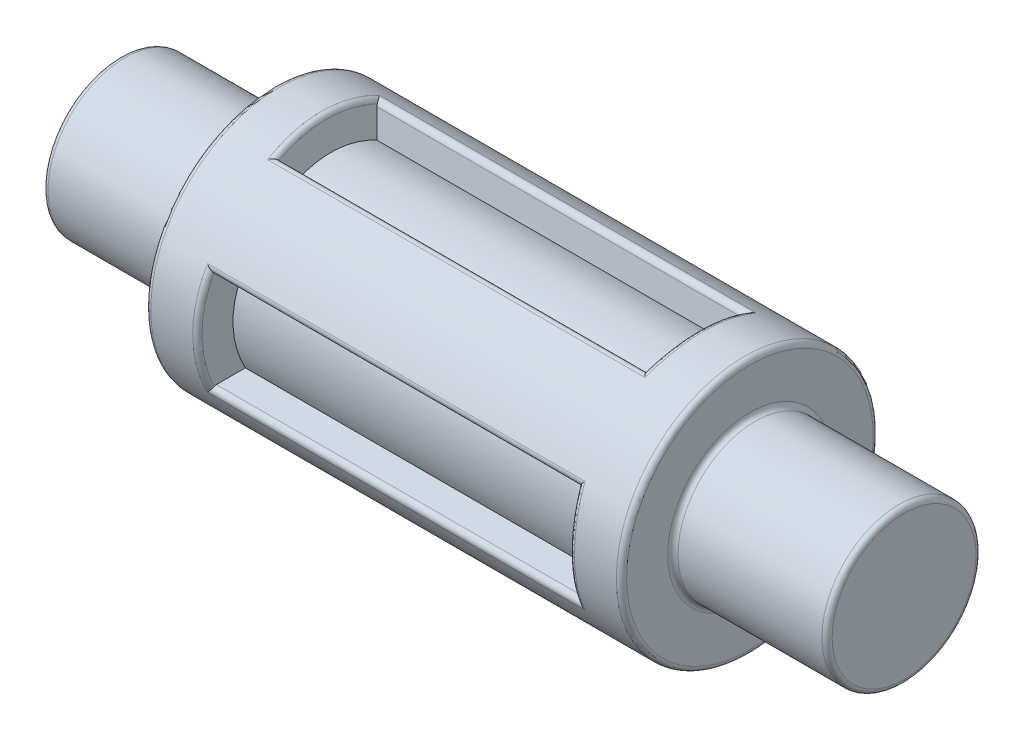
from build123d import *

# Parameters (mm, degrees)
FILLET1_R                   = 0.1
SKETCH2_W                   = 7.26
SKETCH2_H                   = 2
CUT_EXTRUDE1_DEPTH          = 0.8
CUT_EXTRUDE1_DRAFT          = -10
FILLET2_R                   = 0.1
CIRPATTERN1_COPY_1_SKETCH_W = 7.26
CIRPATTERN1_COPY_1_SKETCH_H = 2
CIRPATTERN1_COPY_1_DEPTH    = 0.8
CIRPATTERN1_COPY_1_DRAFT    = -10
CIRPATTERN1_COPY_2_SKETCH_W = 7.26
CIRPATTERN1_COPY_2_SKETCH_H = 2
CIRPATTERN1_COPY_2_DEPTH    = 0.8
CIRPATTERN1_COPY_2_DRAFT    = -10
CIRPATTERN1_COPY_3_SKETCH_W = 7.26
CIRPATTERN1_COPY_3_SKETCH_H = 2
CIRPATTERN1_COPY_3_DEPTH    = 0.8
CIRPATTERN1_COPY_3_DRAFT    = -10
FILLET2_OF_CIRPATTERN1_R    = 0.1
BOSS_EXTRUDE1_REACH         = 14.76
SKETCH3_R                   = 1.904671941


with BuildPart() as part:
    # Sketch1 → Revolve1 (revolve)
    with BuildSketch(Plane(origin=(0, 0, 0), x_dir=(1, 0, 0), z_dir=(0, 1, 0)), mode=Mode.PRIVATE) as revolve1_sk:
        Polygon((0, 0), (0, 1.5), (3, 1.5), (3, 2.5), (12.26, 2.5), (12.26, 1.5), (15.26, 1.5), (15.26, 0), align=None)
    revolve(revolve1_sk.sketch.rotate(Axis((0, 0, 0), (1, 0, 0)), 180), axis=Axis((0, 0, 0), (1, 0, 0)))

    # Fillet1
    fillet1_edges = [part.edges().sort_by_distance(p)[0] for p in [
        (15.26, 0, -1.5),
        (12.26, 0, -1.5),
        (12.26, 0, -2.5),
        (3, 0, -2.5),
        (3, 0, -1.5),
        (0, 0, -1.5),
    ]]
    fillet(fillet1_edges, radius=FILLET1_R)


with BuildPart() as cut_extrude1_tool:
    # Sketch2 → Cut-Extrude1 (with draft: the straight prism first)
    with BuildSketch(Plane(origin=(0, 2.5, 0), x_dir=(-1, 0, 0), z_dir=(0, 1, 0))):
        with Locations((-7.63, 0)):
            Rectangle(SKETCH2_W, SKETCH2_H)
    extrude(amount=-CUT_EXTRUDE1_DEPTH)
    # Cut-Extrude1: the draft: its side faces are tilted about the plane it starts from
    cut_extrude1_sides = [cut_extrude1_tool.faces().sort_by_distance(p)[0] for p in [
        (7.63, 2.1, -1),
        (4, 2.1, 0),
        (7.63, 2.1, 1),
        (11.26, 2.1, 0),
    ]]
    draft(cut_extrude1_sides, Plane(origin=(0, 2.5, 0), x_dir=(-1, 0, 0), z_dir=(0, 1, 0)), CUT_EXTRUDE1_DRAFT)


with BuildPart() as part_1:
    add(part.part)

    # Cut-Extrude1: cut by cut_extrude1_tool
    add(cut_extrude1_tool.part, mode=Mode.SUBTRACT)

    # Fillet2
    fillet2_edges = [part_1.edges().sort_by_distance(p)[0] for p in [
        (11.251349876, 2.45094271, 0.492828398),
        (4.008650124, 2.45094271, 0.492828398),
        (7.63, 2.305920994, 0.965778635),
        (7.63, 2.305920994, -0.965778635),
    ]]
    fillet(fillet2_edges, radius=FILLET2_R)


with BuildPart() as cirpattern1_copy_1_tool:
    # CirPattern1 copy 1 sketch → CirPattern1 copy 1 (with draft: the straight prism first)
    with BuildSketch(Plane(origin=(0, 0, 2.5), x_dir=(-1, 0, 0), z_dir=(0, 0, 1))):
        with Locations((-7.63, 0)):
            Rectangle(CIRPATTERN1_COPY_1_SKETCH_W, CIRPATTERN1_COPY_1_SKETCH_H)
    extrude(amount=-CIRPATTERN1_COPY_1_DEPTH)
    # CirPattern1 copy 1: the draft: its side faces are tilted about the plane it starts from
    cirpattern1_copy_1_sides = [cirpattern1_copy_1_tool.faces().sort_by_distance(p)[0] for p in [
        (7.63, 1, 2.1),
        (4, 0, 2.1),
        (7.63, -1, 2.1),
        (11.26, 0, 2.1),
    ]]
    draft(cirpattern1_copy_1_sides, Plane(origin=(0, 0, 2.5), x_dir=(-1, 0, 0), z_dir=(0, 0, 1)), CIRPATTERN1_COPY_1_DRAFT)


with BuildPart() as part_2:
    add(part_1.part)

    # CirPattern1 copy 1: cut by cirpattern1_copy_1_tool
    add(cirpattern1_copy_1_tool.part, mode=Mode.SUBTRACT)


with BuildPart() as cirpattern1_copy_2_tool:
    # CirPattern1 copy 2 sketch → CirPattern1 copy 2 (with draft: the straight prism first)
    with BuildSketch(Plane(origin=(0, -2.5, 0), x_dir=(-1, 0, 0), z_dir=(0, -1, 0))):
        with Locations((-7.63, 0)):
            Rectangle(CIRPATTERN1_COPY_2_SKETCH_W, CIRPATTERN1_COPY_2_SKETCH_H)
    extrude(amount=-CIRPATTERN1_COPY_2_DEPTH)
    # CirPattern1 copy 2: the draft: its side faces are tilted about the plane it starts from
    cirpattern1_copy_2_sides = [cirpattern1_copy_2_tool.faces().sort_by_distance(p)[0] for p in [
        (7.63, -2.1, 1),
        (4, -2.1, 0),
        (7.63, -2.1, -1),
        (11.26, -2.1, 0),
    ]]
    draft(cirpattern1_copy_2_sides, Plane(origin=(0, -2.5, 0), x_dir=(-1, 0, 0), z_dir=(0, -1, 0)), CIRPATTERN1_COPY_2_DRAFT)


with BuildPart() as part_3:
    add(part_2.part)

    # CirPattern1 copy 2: cut by cirpattern1_copy_2_tool
    add(cirpattern1_copy_2_tool.part, mode=Mode.SUBTRACT)


with BuildPart() as cirpattern1_copy_3_tool:
    # CirPattern1 copy 3 sketch → CirPattern1 copy 3 (with draft: the straight prism first)
    with BuildSketch(Plane(origin=(0, 0, -2.5), x_dir=(-1, 0, 0), z_dir=(0, 0, -1))):
        with Locations((-7.63, 0)):
            Rectangle(CIRPATTERN1_COPY_3_SKETCH_W, CIRPATTERN1_COPY_3_SKETCH_H)
    extrude(amount=-CIRPATTERN1_COPY_3_DEPTH)
    # CirPattern1 copy 3: the draft: its side faces are tilted about the plane it starts from
    cirpattern1_copy_3_sides = [cirpattern1_copy_3_tool.faces().sort_by_distance(p)[0] for p in [
        (7.63, -1, -2.1),
        (4, 0, -2.1),
        (7.63, 1, -2.1),
        (11.26, 0, -2.1),
    ]]
    draft(cirpattern1_copy_3_sides, Plane(origin=(0, 0, -2.5), x_dir=(-1, 0, 0), z_dir=(0, 0, -1)), CIRPATTERN1_COPY_3_DRAFT)


with BuildPart() as part_4:
    add(part_3.part)

    # CirPattern1 copy 3: cut by cirpattern1_copy_3_tool
    add(cirpattern1_copy_3_tool.part, mode=Mode.SUBTRACT)

    # Fillet2 of CirPattern1
    fillet2_of_cirpattern1_edges = [part_4.edges().sort_by_distance(p)[0] for p in [
        (11.251349876, -0.492828398, 2.45094271),
        (4.008650124, -0.492828398, 2.45094271),
        (7.63, -0.965778635, 2.305920994),
        (7.63, 0.965778635, 2.305920994),
        (11.251349876, -2.45094271, -0.492828398),
        (4.008650124, -2.45094271, -0.492828398),
        (7.63, -2.305920994, -0.965778635),
        (7.63, -2.305920994, 0.965778635),
        (11.251349876, 0.492828398, -2.45094271),
        (4.008650124, 0.492828398, -2.45094271),
        (7.63, 0.965778635, -2.305920994),
        (7.63, -0.965778635, -2.305920994),
    ]]
    fillet(fillet2_of_cirpattern1_edges, radius=FILLET2_OF_CIRPATTERN1_R)

    # Boss-Extrude1: up to this face of the body (flat: up to its plane)
    boss_extrude1_end = Plane(part_4.part.faces().sort_by_distance((12.26, 0, -1.667882251))[0])
    # Sketch3 → Boss-Extrude1 (add, up to the picked face)
    with BuildSketch(Plane.ZY.offset(-3), mode=Mode.PRIVATE) as boss_extrude1_sk1:
        Circle(SKETCH3_R)
    boss_extrude1_tool1 = split(extrude(boss_extrude1_sk1.sketch, amount=-BOSS_EXTRUDE1_REACH, mode=Mode.PRIVATE), bisect_by=boss_extrude1_end, keep=Keep.BOTH, mode=Mode.PRIVATE)
    add(boss_extrude1_tool1.solids().sort_by(Axis((3, 0, 0), (1, 0, 0)))[0])


solid = part_4.part
